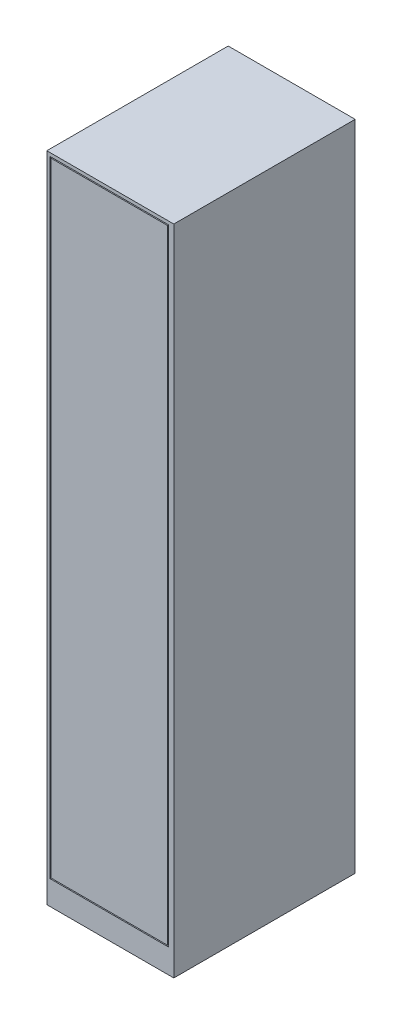
from build123d import *

# Parameters (mm, degrees)
SKETCH1_W               = 350
SKETCH1_H               = 1800
BOSS_EXTRUDE1_DEPTH     = 500
SKETCH2_W               = 327.095698038
SKETCH2_H               = 1724.237144731
SKETCH2_W_2             = 321.095698038
SKETCH2_H_2             = 1718.237144731
CUT_EXTRUDE_THIN1_DEPTH = 3


with BuildPart() as part:
    # Sketch1 → Boss-Extrude1 (new body)
    with BuildSketch(Plane.XY):
        with Locations((175, 900)):
            Rectangle(SKETCH1_W, SKETCH1_H)
    extrude(amount=BOSS_EXTRUDE1_DEPTH)

    # Sketch2 → Cut-Extrude-Thin1 (cut)
    with BuildSketch(Plane.XY.offset(500)):
        with Locations((172.376845805, 928.732453694)):
            Rectangle(SKETCH2_W, SKETCH2_H)
        with Locations((172.376845805, 928.732453694)):
            Rectangle(SKETCH2_W_2, SKETCH2_H_2, mode=Mode.SUBTRACT)
    extrude(amount=-CUT_EXTRUDE_THIN1_DEPTH, mode=Mode.SUBTRACT)


solid = part.part
